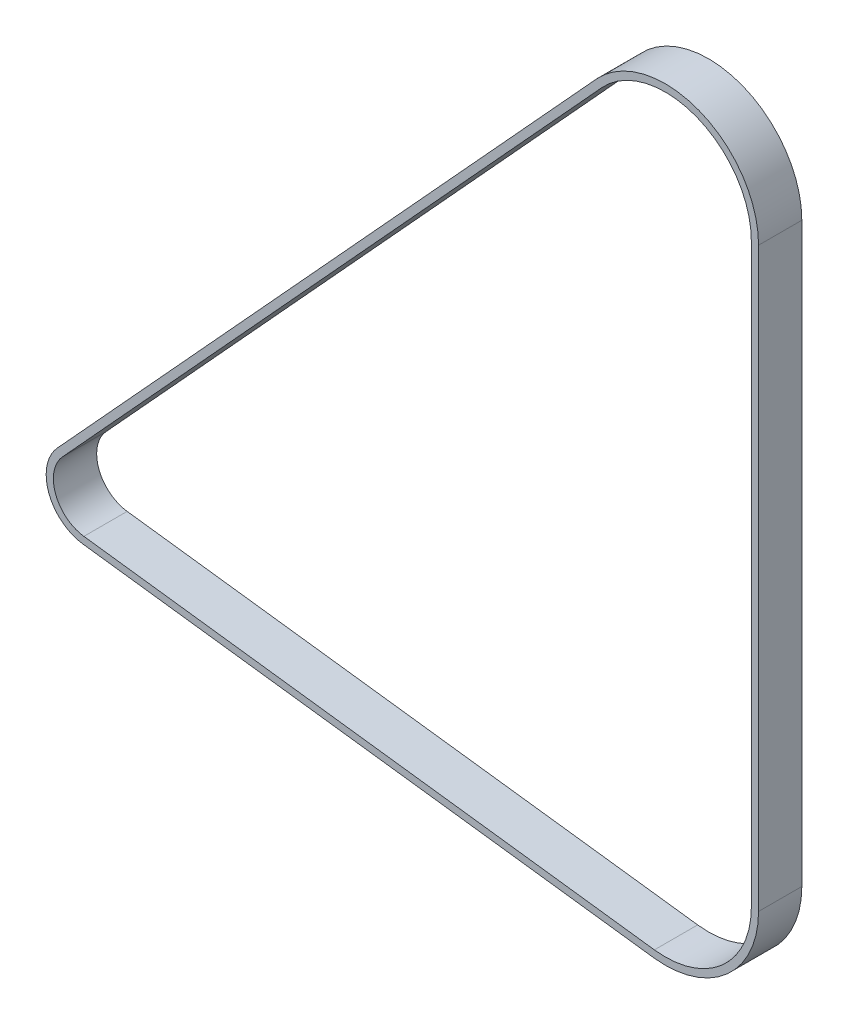
from build123d import *

# Parameters (mm, degrees)
EXTRUDE_THIN1_DEPTH = 4.7625


with BuildPart() as part:
    # Sketch2 → Extrude-Thin1 (new, symmetric)
    with BuildSketch(Plane.XY):
        with BuildLine():
            Line((111.855179593, 135.97990781), (-6.844144428, 6.262824417))
            ThreePointArc((-6.844144428, 6.262824417), (-8.71041734, -3.192790691), (-1.17539795, -9.202375905))
            Line((-1.17539795, -9.202375905), (124.399062652, -25.241708037))
            ThreePointArc((124.399062652, -25.241708037), (140.565197037, -20.286613366), (147.528582468, -4.878559384))
            Line((147.528582468, -4.878559384), (147.528582468, 122.121440616))
            ThreePointArc((147.528582468, 122.121440616), (134.433740763, 141.256805687), (111.855179593, 135.97990781))
        make_face()
        with BuildLine():
            Line((113.02634679, 134.908215855), (-5.672977231, 5.191132462))
            ThreePointArc((-5.672977231, 5.191132462), (-7.219894284, -2.646441653), (-0.974264333, -7.627669101))
            Line((-0.974264333, -7.627669101), (124.600196269, -23.667001233))
            ThreePointArc((124.600196269, -23.667001233), (139.516184017, -19.095089999), (145.941082468, -4.878559384))
            Line((145.941082468, -4.878559384), (145.941082468, 122.121440616))
            ThreePointArc((145.941082468, 122.121440616), (133.858880639, 139.777044866), (113.02634679, 134.908215855))
        make_face(mode=Mode.SUBTRACT)
    extrude(amount=EXTRUDE_THIN1_DEPTH, both=True)


solid = part.part
